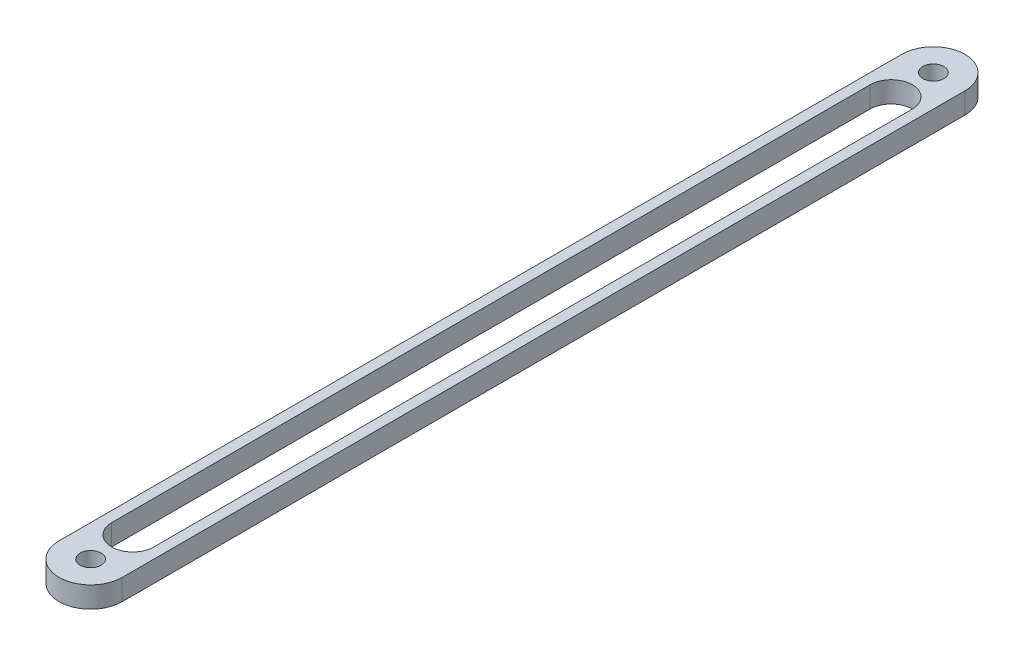
from build123d import *

# Parameters (mm, degrees)
SKETCH1_R           = 1.25
BOSS_EXTRUDE1_DEPTH = 2.5


with BuildPart() as part:
    # Sketch1 → Boss-Extrude1 (new body)
    with BuildSketch(Plane(origin=(0, 0, 0), x_dir=(1, 0, 0), z_dir=(0, 1, 0))):
        with BuildLine():
            Line((0, 0), (0, 100))
            ThreePointArc((0, 100), (3.75, 103.75), (7.5, 100))
            Line((7.5, 100), (7.5, 0))
            ThreePointArc((7.5, 0), (3.75, -3.75), (0, 0))
        make_face()
        with Locations((3.75, 0)):
            Circle(SKETCH1_R, mode=Mode.SUBTRACT)
        with Locations((3.75, 100)):
            Circle(SKETCH1_R, mode=Mode.SUBTRACT)
        with BuildLine():
            Line((1.25, 95), (1.25, 5))
            ThreePointArc((1.25, 5), (3.75, 2.5), (6.25, 5))
            Line((6.25, 5), (6.25, 95))
            ThreePointArc((6.25, 95), (3.75, 97.5), (1.25, 95))
        make_face(mode=Mode.SUBTRACT)
    extrude(amount=BOSS_EXTRUDE1_DEPTH)


solid = part.part
